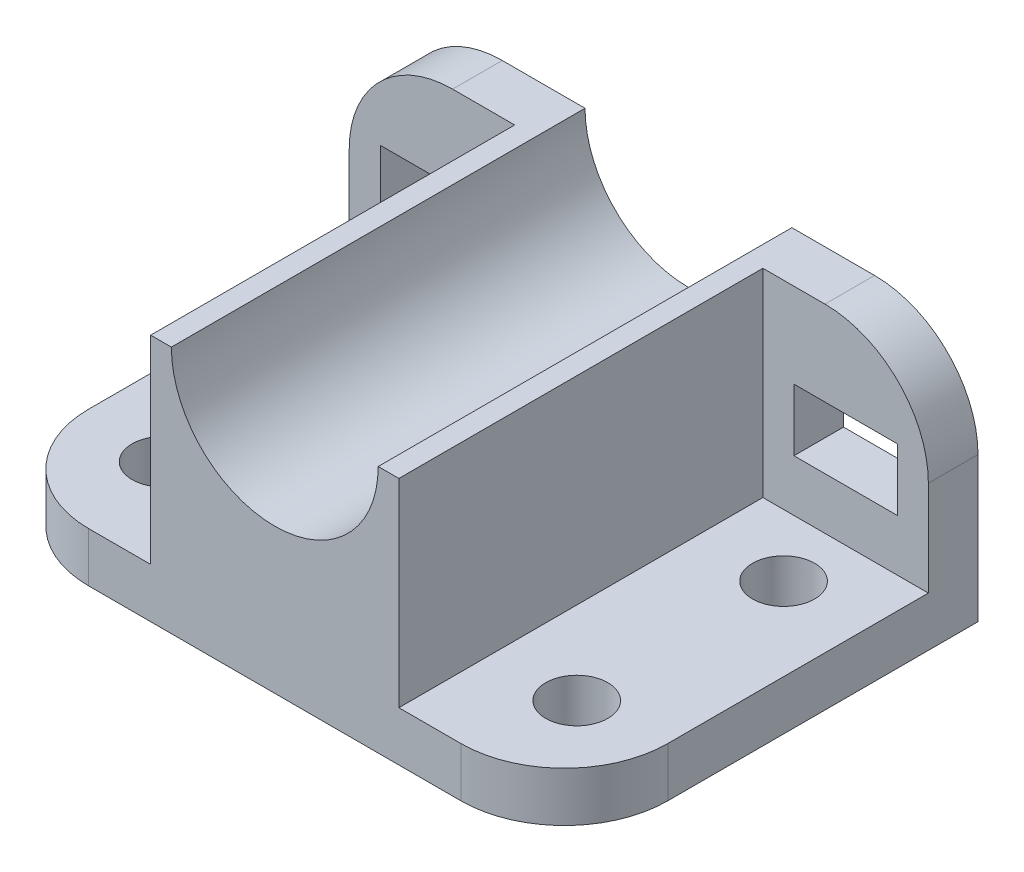
from build123d import *

# Parameters (mm, degrees)
BOSS_EXTRUDE2_DEPTH       = 12
BOSS_EXTRUDE3_DEPTH       = 12
BOSS_EXTRUDE6_DEPTH       = 100
SKETCH5_R                 = 25
CUT_EXTRUDE1_DEPTH        = 100
SKETCH7_R                 = 7.5
CUT_EXTRUDE2_DEPTH        = 100
LPATTERN2_COUNT           = 2
LPATTERN2_PITCH           = 50
LPATTERN5_COUNT           = 2
LPATTERN5_PITCH           = 100
LPATTERN6_COPY_1_SKETCH_R = 7.5
LPATTERN6_COPY_1_DEPTH    = 100
LPATTERN6_COPY_2_SKETCH_R = 7.5
LPATTERN6_COPY_2_DEPTH    = 100
SKETCH8_W                 = 25
SKETCH8_H                 = 15
CUT_EXTRUDE3_DEPTH        = 100


with BuildPart() as part:
    # Sketch1 → Boss-Extrude2 (new body)
    with BuildSketch(Plane(origin=(0, 0, 0), x_dir=(1, 0, 0), z_dir=(0, 1, 0))):
        with BuildLine():
            Line((-70, 50), (70, 50))
            Line((70, 50), (70, -25))
            ThreePointArc((70, -25), (62.67766953, -42.67766953), (45, -50))
            Line((45, -50), (-45, -50))
            ThreePointArc((-45, -50), (-62.67766953, -42.67766953), (-70, -25))
            Line((-70, -25), (-70, 50))
        make_face()
    extrude(amount=BOSS_EXTRUDE2_DEPTH)

    # Sketch2 → Boss-Extrude3 (add)
    with BuildSketch(Plane(origin=(0, 0, -50), x_dir=(-1, 0, 0), z_dir=(0, 0, -1))):
        with BuildLine():
            Line((-70, 12), (-70, 35))
            ThreePointArc((-70, 35), (-62.67766953, 52.67766953), (-45, 60))
            Line((-45, 60), (45, 60))
            ThreePointArc((45, 60), (62.67766953, 52.67766953), (70, 35))
            Line((70, 35), (70, 12))
            Line((70, 12), (-70, 12))
        make_face()
    extrude(amount=-BOSS_EXTRUDE3_DEPTH)

    # Sketch4 → Boss-Extrude6 (add)
    with BuildSketch(Plane(origin=(0, 0, -50), x_dir=(-1, 0, 0), z_dir=(0, 0, -1))):
        with BuildLine():
            Line((-25, 60), (-30, 60))
            Line((-30, 60), (-30, 12))
            Line((-30, 12), (30, 12))
            Line((30, 12), (30, 60))
            Line((30, 60), (25, 60))
            ThreePointArc((25, 60), (0, 35), (-25, 60))
        make_face()
    extrude(amount=-BOSS_EXTRUDE6_DEPTH)

    # Sketch5 → Cut-Extrude1 (cut)
    with BuildSketch(Plane.XY.offset(-38)):
        with Locations((0, 60)):
            Circle(SKETCH5_R)
    extrude(amount=-CUT_EXTRUDE1_DEPTH, mode=Mode.SUBTRACT)

    # Sketch7 → Cut-Extrude2 (cut)
    with BuildSketch(Plane(origin=(0, 12, 0), x_dir=(1, 0, 0), z_dir=(0, 1, 0))):
        with Locations((50, 23)):
            Circle(SKETCH7_R)
    cut_extrude2 = extrude(amount=-CUT_EXTRUDE2_DEPTH, mode=Mode.SUBTRACT)

    # LPattern2: Cut-Extrude2 ×2
    with Locations(*[(0, 0, i * LPATTERN2_PITCH) for i in range(1, LPATTERN2_COUNT)]):
        add(cut_extrude2, mode=Mode.SUBTRACT)

    # LPattern5: Cut-Extrude2 ×2
    with Locations(*[(-i * LPATTERN5_PITCH, 0, 0) for i in range(1, LPATTERN5_COUNT)]):
        add(cut_extrude2, mode=Mode.SUBTRACT)

    # LPattern6 copy 1 sketch → LPattern6 copy 1 (cut)
    with BuildSketch(Plane(origin=(-100, 12, 50), x_dir=(1, 0, 0), z_dir=(0, 1, 0))):
        with Locations((50, 23)):
            Circle(LPATTERN6_COPY_1_SKETCH_R)
    extrude(amount=-LPATTERN6_COPY_1_DEPTH, mode=Mode.SUBTRACT)

    # LPattern6 copy 2 sketch → LPattern6 copy 2 (cut)
    with BuildSketch(Plane(origin=(0, 12, 50), x_dir=(1, 0, 0), z_dir=(0, 1, 0))):
        with Locations((50, 23)):
            Circle(LPATTERN6_COPY_2_SKETCH_R)
    extrude(amount=-LPATTERN6_COPY_2_DEPTH, mode=Mode.SUBTRACT)

    # Sketch8 → Cut-Extrude3 (cut)
    with BuildSketch(Plane.XY.offset(-38)):
        with Locations((50, 32)):
            Rectangle(SKETCH8_W, SKETCH8_H)
        with Locations((-50, 32)):
            Rectangle(SKETCH8_W, SKETCH8_H)
    extrude(amount=-CUT_EXTRUDE3_DEPTH, mode=Mode.SUBTRACT)


solid = part.part
